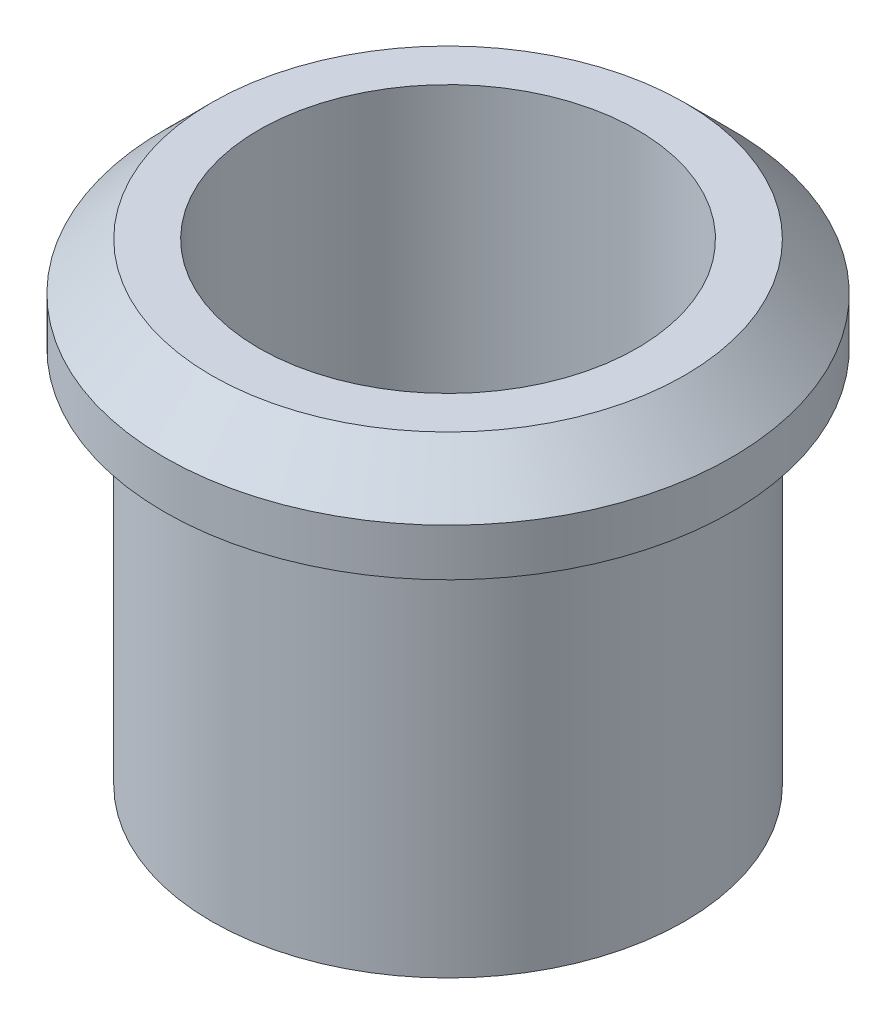
from build123d import *

# Parameters (mm, degrees)
SKETCH2_R           = 2.5
SKETCH2_R_2         = 2
BOSS_EXTRUDE1_DEPTH = 4
SKETCH3_R           = 3
SKETCH3_R_2         = 2
BOSS_EXTRUDE2_DEPTH = 1
CHAMFER1_SIZE       = 0.5


with BuildPart() as part:
    # Sketch2 → Boss-Extrude1 (new body)
    with BuildSketch(Plane(origin=(0, 0, 0), x_dir=(1, 0, 0), z_dir=(0, 1, 0))):
        Circle(SKETCH2_R)
        Circle(SKETCH2_R_2, mode=Mode.SUBTRACT)
    extrude(amount=BOSS_EXTRUDE1_DEPTH)

    # Sketch3 → Boss-Extrude2 (add)
    with BuildSketch(Plane(origin=(0, 4, 0), x_dir=(1, 0, 0), z_dir=(0, 1, 0))):
        Circle(SKETCH3_R)
        Circle(SKETCH3_R_2, mode=Mode.SUBTRACT)
    extrude(amount=BOSS_EXTRUDE2_DEPTH)

    # Chamfer1
    chamfer1_edges = [part.edges().sort_by_distance(p)[0] for p in [
        (-3, 5, 0),
    ]]
    chamfer(chamfer1_edges, length=CHAMFER1_SIZE)


solid = part.part
